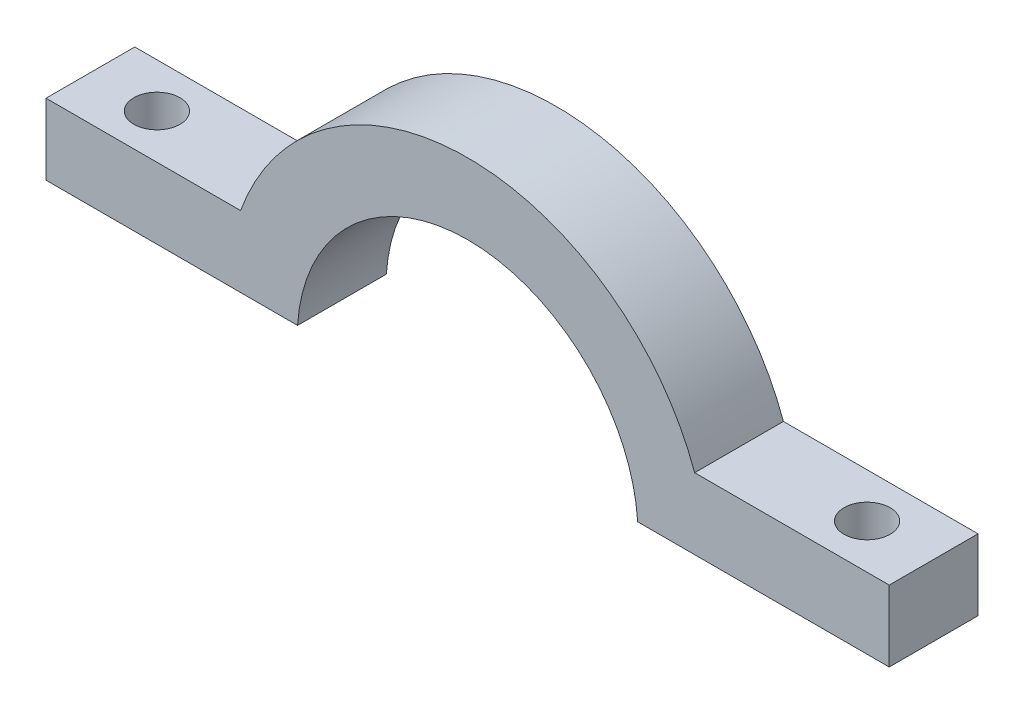
from build123d import *

# Parameters (mm, degrees)
BOSS_EXTRUDE1_DEPTH = 6.35
SKETCH2_R           = 1.651
CUT_EXTRUDE1_DEPTH  = 6.35


with BuildPart() as part:
    # Sketch1 → Boss-Extrude1 (new body)
    with BuildSketch(Plane.XY):
        with BuildLine():
            Line((-16.242568914, 5.87375), (-30.1625, 5.87375))
            Line((-30.1625, 5.87375), (-30.1625, 0.79375))
            Line((-30.1625, 0.79375), (-12.166134347, 0.79375))
            ThreePointArc((-12.166134347, 0.79375), (0, 12.192), (12.166134347, 0.79375))
            Line((12.166134347, 0.79375), (30.1625, 0.79375))
            Line((30.1625, 0.79375), (30.1625, 5.87375))
            Line((30.1625, 5.87375), (16.242568914, 5.87375))
            ThreePointArc((16.242568914, 5.87375), (0, 17.272), (-16.242568914, 5.87375))
        make_face()
    extrude(amount=BOSS_EXTRUDE1_DEPTH)

    # Sketch2 → Cut-Extrude1 (cut)
    with BuildSketch(Plane(origin=(0, 5.87375, 0), x_dir=(1, 0, 0), z_dir=(0, 1, 0))):
        with Locations((-25.4, -3.175)):
            Circle(SKETCH2_R)
        with Locations((25.4, -3.175)):
            Circle(SKETCH2_R)
    extrude(amount=-CUT_EXTRUDE1_DEPTH, mode=Mode.SUBTRACT)


solid = part.part
